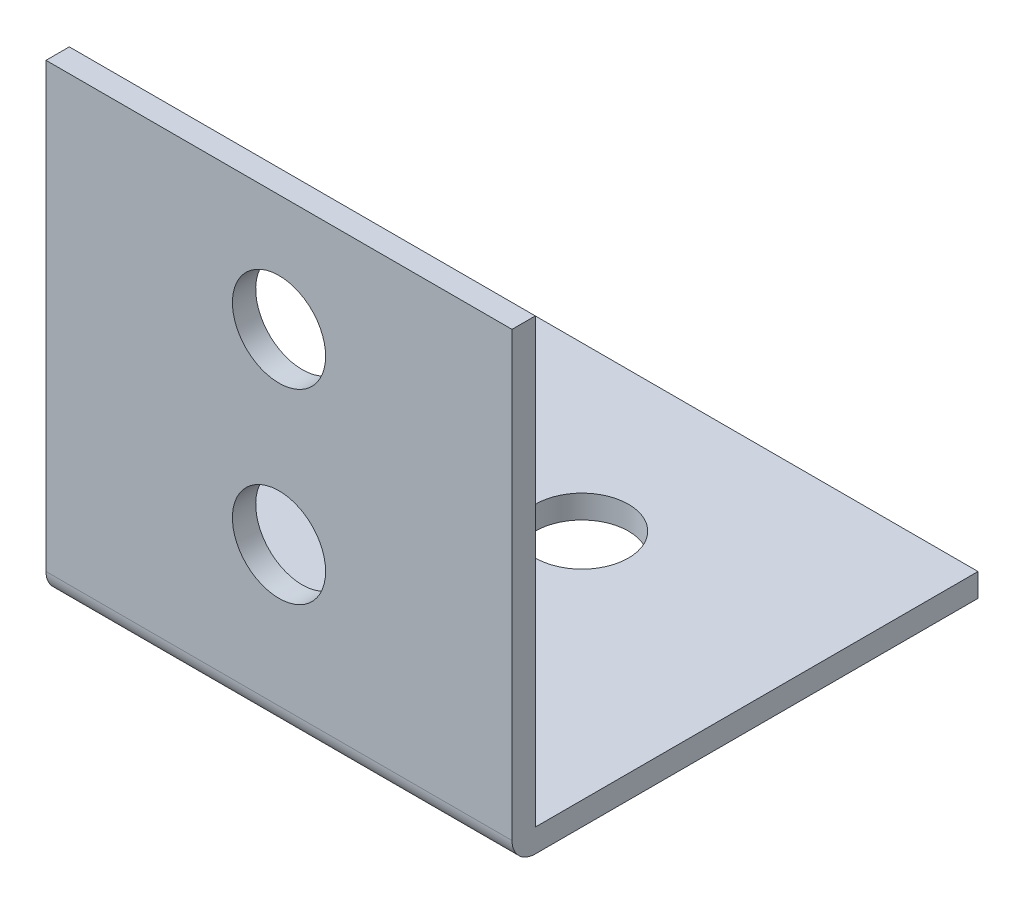
from build123d import *

# Parameters (mm, degrees)
BOSS_EXTRUDE1_DEPTH = 10
SKETCH2_R           = 2
CUT_EXTRUDE1_DEPTH  = 20
SKETCH3_R           = 2
CUT_EXTRUDE2_DEPTH  = 20


with BuildPart() as part:
    # Sketch1 → Boss-Extrude1 (new, symmetric)
    with BuildSketch(Plane(origin=(0, 0, 0), x_dir=(0, 0, -1), z_dir=(1, 0, 0))):
        with BuildLine():
            Line((20, 0), (1, 0))
            ThreePointArc((1, 0), (0.292893219, 0.292893219), (0, 1))
            Line((0, 1), (0, 20))
            Line((0, 20), (1, 20))
            Line((1, 20), (1, 1))
            Line((1, 1), (20, 1))
            Line((20, 1), (20, 0))
        make_face()
    extrude(amount=BOSS_EXTRUDE1_DEPTH, both=True)

    # Sketch2 → Cut-Extrude1 (cut)
    with BuildSketch(Plane.XY):
        with Locations((0, 7)):
            Circle(SKETCH2_R)
        with Locations((0, 15)):
            Circle(SKETCH2_R)
    extrude(amount=-CUT_EXTRUDE1_DEPTH, mode=Mode.SUBTRACT)

    # Sketch3 → Cut-Extrude2 (cut)
    with BuildSketch(Plane.XZ):
        with Locations(Location((0, -13, 0), (0, 0, 270))):
            Circle(SKETCH3_R)
        with Locations(Location((0, -5, 0), (0, 0, 270))):
            Circle(SKETCH3_R)
    extrude(amount=-CUT_EXTRUDE2_DEPTH, mode=Mode.SUBTRACT)


solid = part.part
